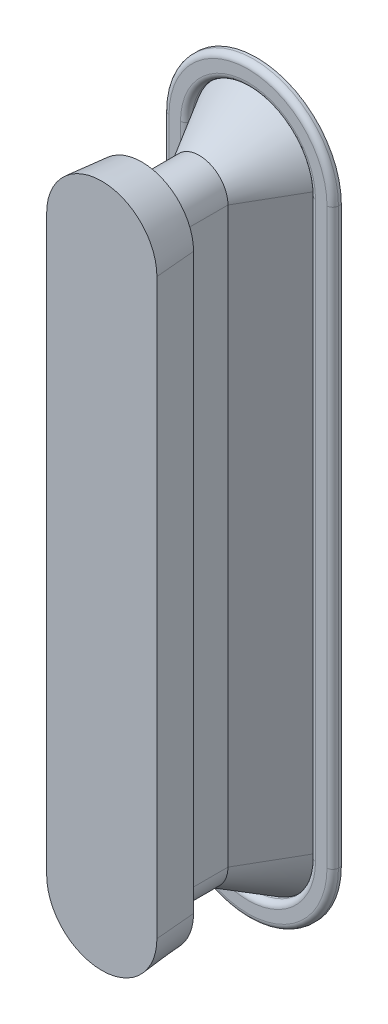
from build123d import *

# Parameters (mm, degrees)
BOSS_EXTRUDE1_DEPTH           = 20
BOSS_EXTRUDE1_OTHER_WAY_DEPTH = 20
BOSS_EXTRUDE1_OTHER_WAY_TAPER = -30
BOSS_EXTRUDE2_DEPTH           = 3
FILLET1_R                     = 2
BOSS_EXTRUDE4_DEPTH           = 14
BOSS_EXTRUDE4_TAPER           = -5


with BuildPart() as part:
    # Sketch1 → Boss-Extrude1 (new body)
    with BuildSketch(Plane.XY):
        with BuildLine():
            ThreePointArc((-10, -100), (0, -110), (10, -100))
            Line((10, -100), (10, 100))
            ThreePointArc((10, 100), (0, 110), (-10, 100))
            Line((-10, 100), (-10, -100))
        make_face()
    extrude(amount=BOSS_EXTRUDE1_DEPTH)

    # Sketch1 → Boss-Extrude1 other way (add)
    with BuildSketch(Plane.XY):
        with BuildLine():
            ThreePointArc((-10, -100), (0, -110), (10, -100))
            Line((10, -100), (10, 100))
            ThreePointArc((10, 100), (0, 110), (-10, 100))
            Line((-10, 100), (-10, -100))
        make_face()
    extrude(amount=-BOSS_EXTRUDE1_OTHER_WAY_DEPTH, taper=BOSS_EXTRUDE1_OTHER_WAY_TAPER)

    # Sketch3 → Boss-Extrude4 (add)
    with BuildSketch(Plane.XY.offset(20)):
        with BuildLine():
            Line((18, -100), (18, 100))
            ThreePointArc((18, 100), (0, 118), (-18, 100))
            Line((-18, 100), (-18, -100))
            ThreePointArc((-18, -100), (0, -118), (18, -100))
        make_face()
    extrude(amount=BOSS_EXTRUDE4_DEPTH, taper=BOSS_EXTRUDE4_TAPER)


with BuildPart() as body_2:
    # Sketch2 → Boss-Extrude2 (new body)
    with BuildSketch(Plane(origin=(0, 0, -20), x_dir=(-1, 0, 0), z_dir=(0, 0, -1))):
        with BuildLine():
            Line((-29.547005384, 100), (-29.547005384, -100))
            ThreePointArc((-29.547005384, -100), (0, -129.547005384), (29.547005384, -100))
            Line((29.547005384, -100), (29.547005384, 100))
            ThreePointArc((29.547005384, 100), (0, 129.547005384), (-29.547005384, 100))
        make_face()
        with BuildLine():
            Line((21.547005384, -100), (21.547005384, 100))
            ThreePointArc((21.547005384, 100), (0, 121.547005384), (-21.547005384, 100))
            Line((-21.547005384, 100), (-21.547005384, -100))
            ThreePointArc((-21.547005384, -100), (0, -121.547005384), (21.547005384, -100))
        make_face(mode=Mode.SUBTRACT)
    extrude(amount=-BOSS_EXTRUDE2_DEPTH)

    # Fillet1
    fillet1_edges = [body_2.edges().sort_by_distance(p)[0] for p in [
        (0, -129.547005384, -17),
        (-29.547005384, 0, -17),
        (0, -121.547005384, -17),
        (21.547005384, 0, -17),
        (0, 121.547005384, -17),
        (-21.547005384, 0, -17),
        (0, 129.547005384, -17),
        (29.547005384, 0, -17),
    ]]
    fillet(fillet1_edges, radius=FILLET1_R)


solid = Compound([part.part, body_2.part])
